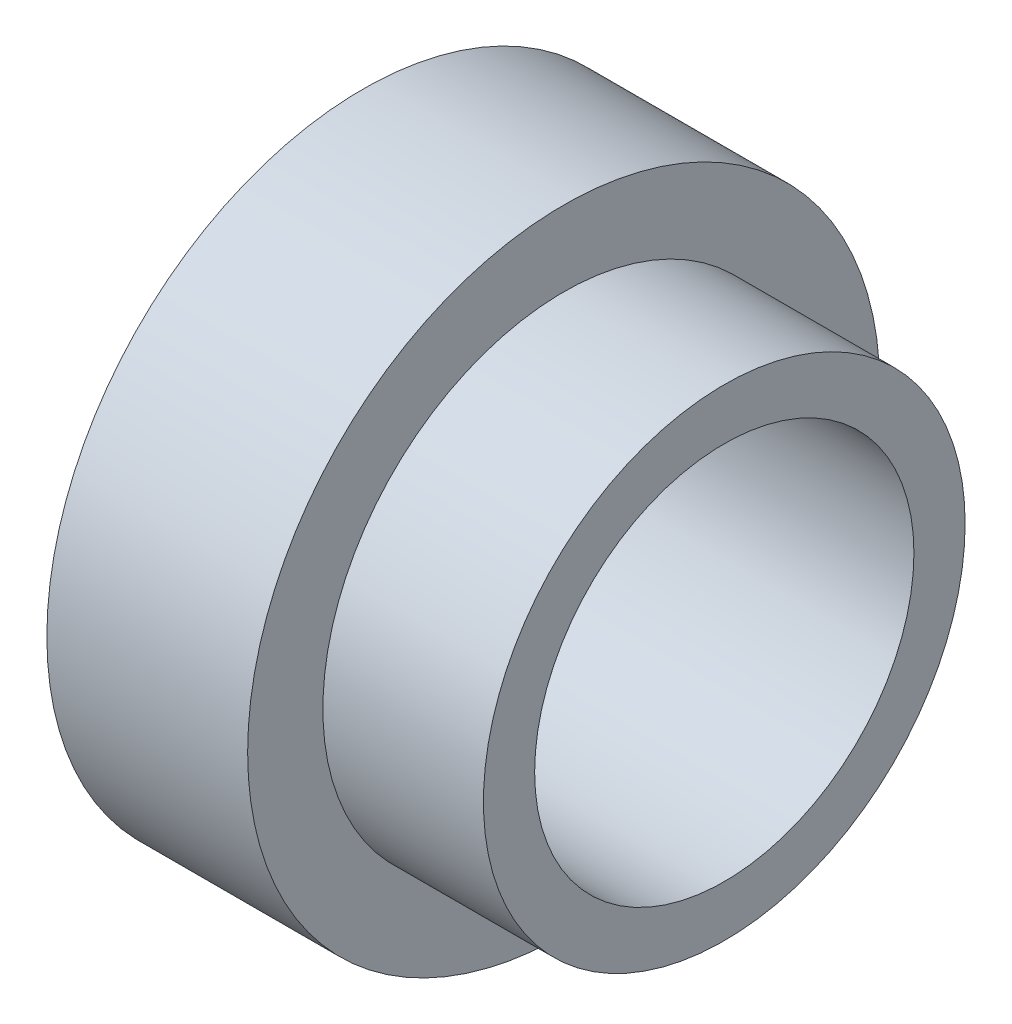
from build123d import *

# Parameters (mm, degrees)
SKETCH1_R           = 12.5
SKETCH1_R_2         = 7.5
BOSS_EXTRUDE1_DEPTH = 7.94
SKETCH2_R           = 9.525
SKETCH2_R_2         = 7.5
BOSS_EXTRUDE2_DEPTH = 6.35


with BuildPart() as part:
    # Sketch1 → Boss-Extrude1 (new body)
    with BuildSketch(Plane(origin=(0, 0, 0), x_dir=(0, 0, -1), z_dir=(1, 0, 0))):
        Circle(SKETCH1_R)
        Circle(SKETCH1_R_2, mode=Mode.SUBTRACT)
    extrude(amount=BOSS_EXTRUDE1_DEPTH)

    # Sketch2 → Boss-Extrude2 (add)
    with BuildSketch(Plane(origin=(7.94, 0, 0), x_dir=(0, 0, -1), z_dir=(1, 0, 0))):
        Circle(SKETCH2_R)
        Circle(SKETCH2_R_2, mode=Mode.SUBTRACT)
    extrude(amount=BOSS_EXTRUDE2_DEPTH)


solid = part.part
